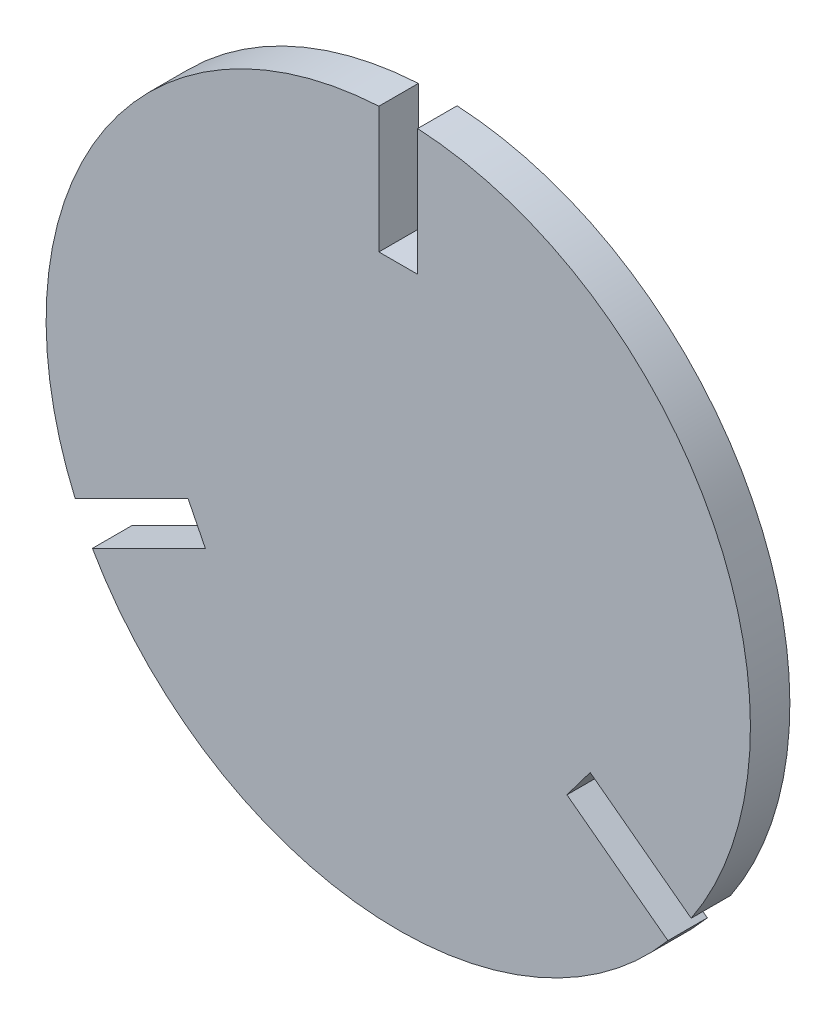
from build123d import *

# Parameters (mm, degrees)
CROQUIS1_R              = 25
SALIENTE_EXTRUIR1_DEPTH = 2.8
CROQUIS2_W              = 2.75
CROQUIS2_H              = 18
CORTAR_EXTRUIR1_DEPTH   = 3.8
MATRIZC2_COUNT          = 3
MATRIZC2_ANGLE          = 233.12


with BuildPart() as part:
    # Croquis1 → Saliente-Extruir1 (new body)
    with BuildSketch(Plane.XY):
        Circle(CROQUIS1_R)
    extrude(amount=SALIENTE_EXTRUIR1_DEPTH)

    # Croquis2 → Cortar-Extruir1 (cut, through all)
    with BuildSketch(Plane.XY):
        with Locations((0, 25)):
            Rectangle(CROQUIS2_W, CROQUIS2_H)
    cortar_extruir1 = extrude(amount=CORTAR_EXTRUIR1_DEPTH, mode=Mode.SUBTRACT)

    # MatrizC2: Cortar-Extruir1 ×3 about axis
    matrizc2_axis = Axis((0, 0, 0), (0, 0, 1))
    for i in range(1, MATRIZC2_COUNT):
        add(cortar_extruir1.rotate(matrizc2_axis, i * MATRIZC2_ANGLE / (MATRIZC2_COUNT - 1)), mode=Mode.SUBTRACT)


solid = part.part
